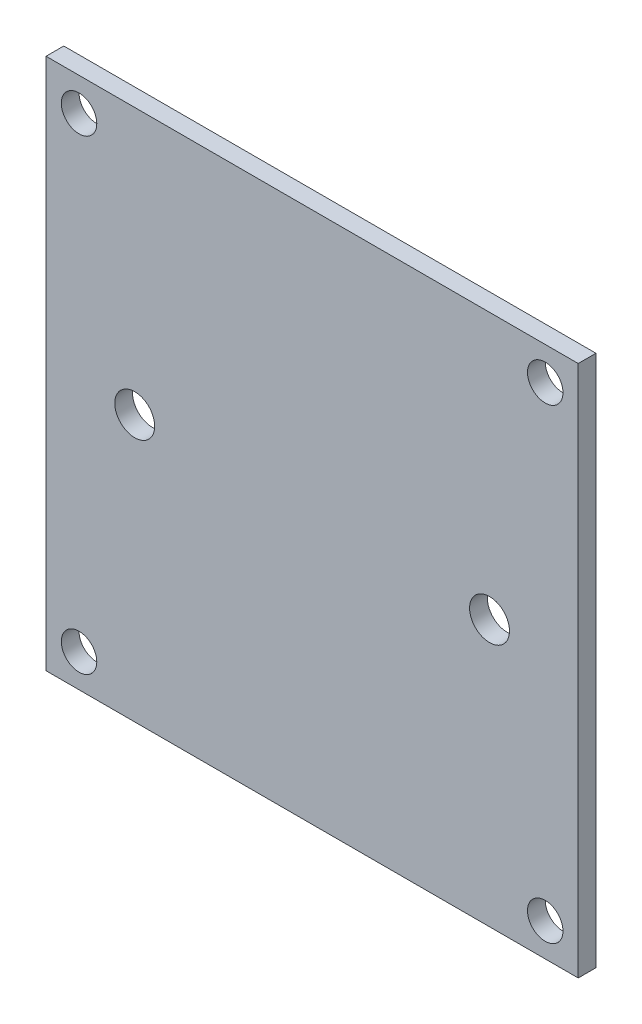
from build123d import *

# Parameters (mm, degrees)
SKETCH1_W           = 30
SKETCH1_H           = 30
BOSS_EXTRUDE1_DEPTH = 1
SKETCH2_R           = 1
SKETCH2_R_2         = 1.125
CUT_EXTRUDE1_DEPTH  = 2


with BuildPart() as part:
    # Sketch1 → Boss-Extrude1 (new body)
    with BuildSketch(Plane.XY):
        Rectangle(SKETCH1_W, SKETCH1_H)
    extrude(amount=BOSS_EXTRUDE1_DEPTH)

    # Sketch2 → Cut-Extrude1 (cut, through all)
    with BuildSketch(Plane.XY.offset(1)):
        with Locations((-13.14, 13.14)):
            Circle(SKETCH2_R)
        with Locations((13.14, 13.14)):
            Circle(SKETCH2_R)
        with Locations((13.14, -13.14)):
            Circle(SKETCH2_R)
        with Locations((-13.14, -13.14)):
            Circle(SKETCH2_R)
        with Locations((-10, 0)):
            Circle(SKETCH2_R_2)
        with Locations((10, 0)):
            Circle(SKETCH2_R_2)
    extrude(amount=-CUT_EXTRUDE1_DEPTH, mode=Mode.SUBTRACT)


solid = part.part
